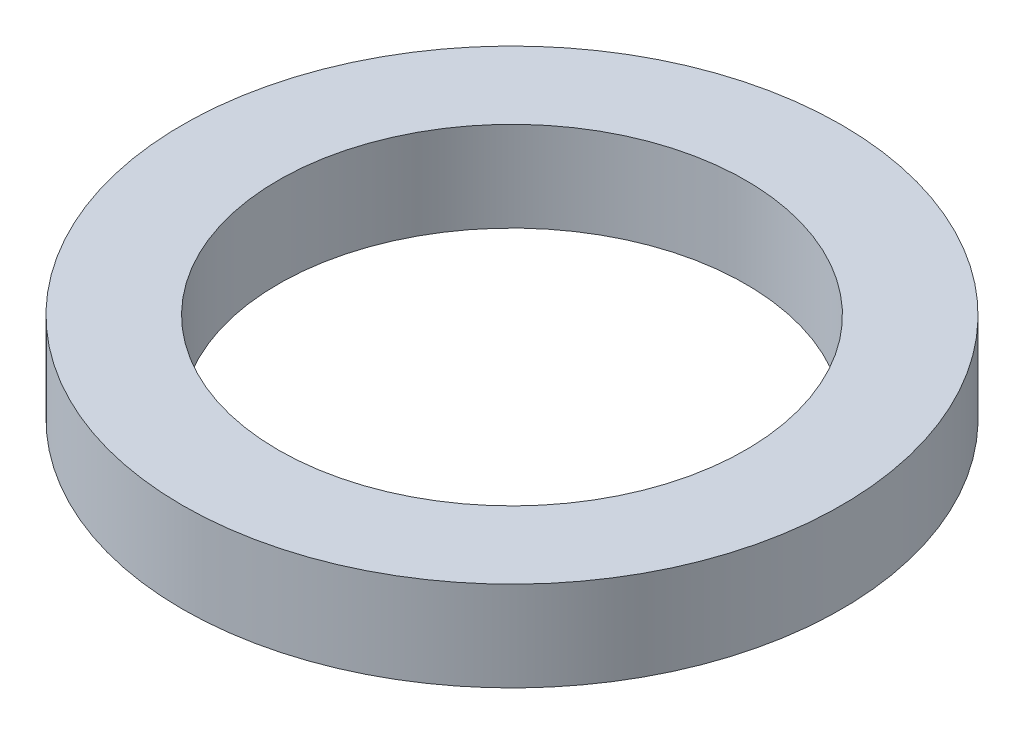
from build123d import *

# Parameters (mm, degrees)
SKETCH1_R           = 13.97
SKETCH1_R_2         = 9.906
BOSS_EXTRUDE1_DEPTH = 3.81


with BuildPart() as part:
    # Sketch1 → Boss-Extrude1 (new body)
    with BuildSketch(Plane(origin=(0, 0, 0), x_dir=(1, 0, 0), z_dir=(0, 1, 0))):
        Circle(SKETCH1_R)
        Circle(SKETCH1_R_2, mode=Mode.SUBTRACT)
    extrude(amount=BOSS_EXTRUDE1_DEPTH)


solid = part.part
